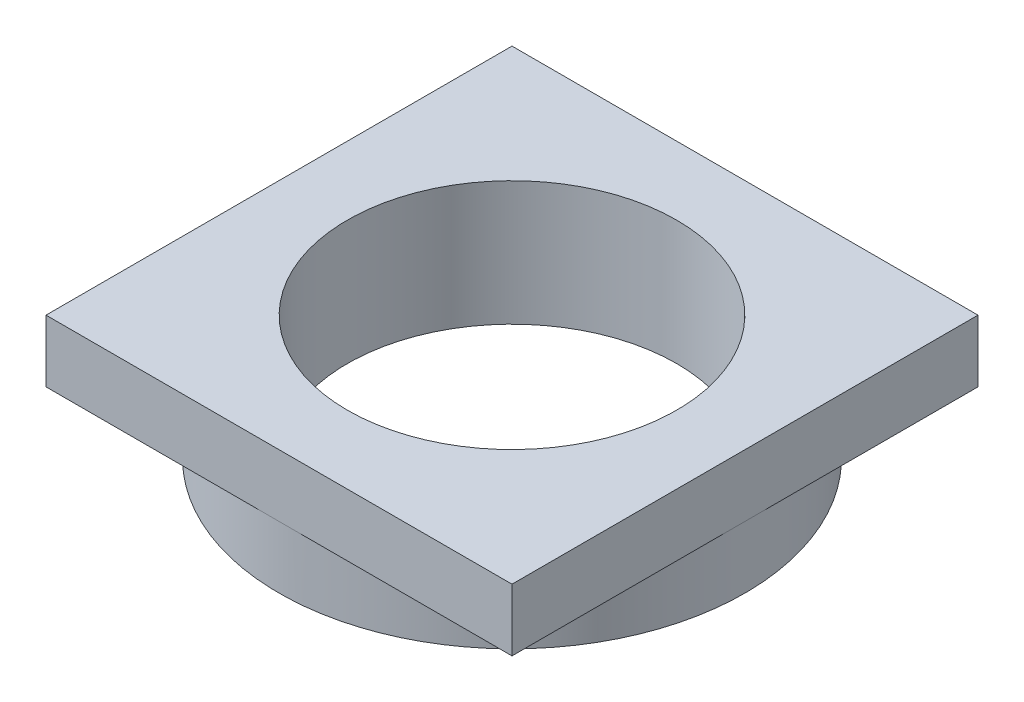
from build123d import *

# Parameters (mm, degrees)
SKETCH1_W           = 75
SKETCH1_H           = 75
SKETCH1_R           = 26.5
BOSS_EXTRUDE1_DEPTH = 10
SKETCH2_R           = 37.5
SKETCH2_R_2         = 26.5
BOSS_EXTRUDE2_DEPTH = 10


with BuildPart() as part:
    # Sketch1 → Boss-Extrude1 (new body)
    with BuildSketch(Plane(origin=(0, 0, 0), x_dir=(1, 0, 0), z_dir=(0, 1, 0))):
        Rectangle(SKETCH1_W, SKETCH1_H)
        Circle(SKETCH1_R, mode=Mode.SUBTRACT)
    extrude(amount=BOSS_EXTRUDE1_DEPTH)

    # Sketch2 → Boss-Extrude2 (add)
    with BuildSketch(Plane.XZ):
        Circle(SKETCH2_R)
        Circle(SKETCH2_R_2, mode=Mode.SUBTRACT)
    extrude(amount=BOSS_EXTRUDE2_DEPTH)


solid = part.part
